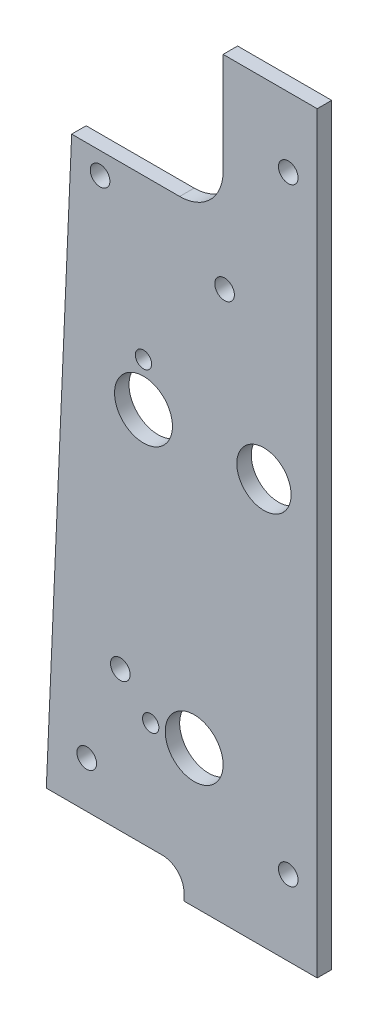
from build123d import *

# Parameters (mm, degrees)
BOSS_EXTRUDE1_DEPTH              = 3.175
F_6_CLEARANCE_HOLE1_D            = 4.3053
F_6_CLEARANCE_HOLE2_D            = 4.3053
F_9_64_0_14063_DIAMETER_HOLE1_D  = 3.572002
F_15_32_0_46875_DIAMETER_HOLE1_D = 11.90625
F_1_2_0_5_DIAMETER_HOLE1_D       = 12.7
CUT_EXTRUDE1_REACH               = 5.175
SKETCH12_W                       = 9.525
SKETCH12_H                       = 31.75
FILLET1_R                        = 9.525


with BuildPart() as part:
    # Sketch1 → Boss-Extrude1 (new body)
    with BuildSketch(Plane.XY):
        with BuildLine():
            Line((-29.21, 1.5875), (-29.21, 0))
            Line((-29.21, 0), (0, 0))
            Line((0, 0), (0, 165.1))
            Line((0, 165.1), (-25.4, 165.1))
            Line((-25.4, 165.1), (-25.4, 138.1125))
            ThreePointArc((-25.4, 138.1125), (-26.794903955, 134.744903955), (-30.1625, 133.35))
            Line((-30.1625, 133.35), (-53.848, 133.35))
            Line((-53.848, 133.35), (-59.411809524, 6.35))
            Line((-59.411809524, 6.35), (-33.9725, 6.35))
            ThreePointArc((-33.9725, 6.35), (-30.604903955, 4.955096045), (-29.21, 1.5875))
        make_face()
    extrude(amount=-BOSS_EXTRUDE1_DEPTH)

    # #6 Clearance Hole1 (through all)
    with Locations(Plane.XY):
        with Locations((-47.625, 128.5875), (-6.35, 149.86), (-50.546, 16.51), (-6.35, 16.51)):
            Hole(F_6_CLEARANCE_HOLE1_D / 2)

    # #6 Clearance Hole2 (through all)
    with Locations(Plane.XY):
        with Locations((-43.18, 37.084), (-20.32, 120.65)):
            Hole(F_6_CLEARANCE_HOLE2_D / 2)

    # 9/64 (0.14063) Diameter Hole1 (through all)
    with Locations(Plane.XY):
        with Locations((-38.1, 98.425), (-36.5125, 30.1625)):
            Hole(F_9_64_0_14063_DIAMETER_HOLE1_D / 2)

    # 15/32 (0.46875) Diameter Hole1 (through all)
    with Locations(Plane.XY):
        with Locations((-11.684, 88.9)):
            Hole(F_15_32_0_46875_DIAMETER_HOLE1_D / 2)

    # 1/2 (0.5) Diameter Hole1 (through all)
    with Locations(Plane.XY):
        with Locations((-38.1, 88.9), (-26.9875, 30.1625)):
            Hole(F_1_2_0_5_DIAMETER_HOLE1_D / 2)

    # Sketch12 → Cut-Extrude1 (cut, up to next)
    with BuildSketch(Plane.XY, mode=Mode.PRIVATE) as cut_extrude1_sk1:
        with Locations((-25.4, 149.225)):
            Rectangle(SKETCH12_W, SKETCH12_H)
    cut_extrude1_tool1 = extrude(cut_extrude1_sk1.sketch, amount=-CUT_EXTRUDE1_REACH, mode=Mode.PRIVATE) & part.part
    add(cut_extrude1_tool1.solids().sort_by_distance((-25.4, 149.225, 0))[0], mode=Mode.SUBTRACT)

    # Fillet1
    fillet1_edges = [part.edges().sort_by_distance(p)[0] for p in [
        (-20.6375, 133.35, -1.5875),
    ]]
    fillet(fillet1_edges, radius=FILLET1_R)


solid = part.part
